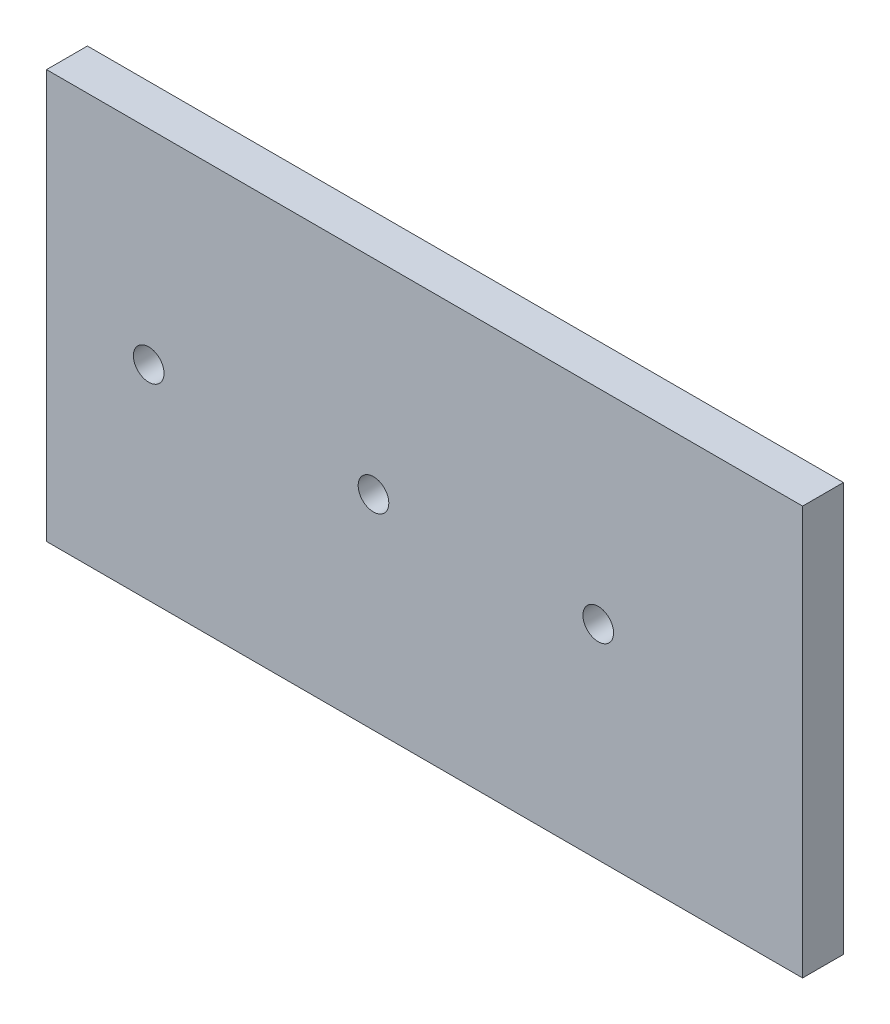
from build123d import *

# Parameters (mm, degrees)
SKETCH1_W           = 234.95
SKETCH1_H           = 127
SKETCH1_R           = 4.7625
BOSS_EXTRUDE1_DEPTH = 12.7


with BuildPart() as part:
    # Sketch1 → Boss-Extrude1 (new body)
    with BuildSketch(Plane.XY):
        with Locations((117.475, 63.5)):
            Rectangle(SKETCH1_W, SKETCH1_H)
        with Locations((31.75, 63.5)):
            Circle(SKETCH1_R, mode=Mode.SUBTRACT)
        with Locations((101.6, 63.5)):
            Circle(SKETCH1_R, mode=Mode.SUBTRACT)
        with Locations((171.45, 63.5)):
            Circle(SKETCH1_R, mode=Mode.SUBTRACT)
    extrude(amount=BOSS_EXTRUDE1_DEPTH)


solid = part.part
